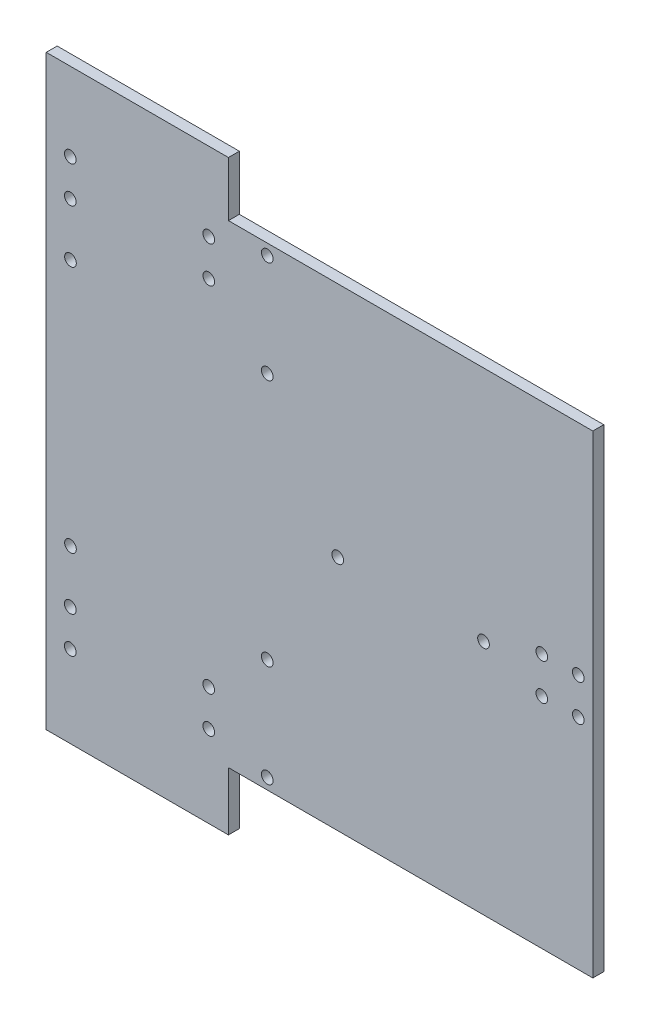
from build123d import *

# Parameters (mm, degrees)
SKETCH1_W           = 150
SKETCH1_H           = 130
BOSS_EXTRUDE1_DEPTH = 3
SKETCH3_W           = 50
SKETCH3_H           = 15
SKETCH3_H_2         = 16
BOSS_EXTRUDE2_DEPTH = 3
SKETCH2_R           = 1.6
CUT_EXTRUDE1_DEPTH  = 10


with BuildPart() as part:
    # Sketch1 → Boss-Extrude1 (new body)
    with BuildSketch(Plane.XY):
        Rectangle(SKETCH1_W, SKETCH1_H)
    extrude(amount=BOSS_EXTRUDE1_DEPTH)

    # Sketch3 → Boss-Extrude2 (add)
    with BuildSketch(Plane(origin=(0, 0, 0), x_dir=(-1, 0, 0), z_dir=(0, 0, -1))):
        with Locations((50, 72.5)):
            Rectangle(SKETCH3_W, SKETCH3_H)
        with Locations((50, -73)):
            Rectangle(SKETCH3_W, SKETCH3_H_2)
    extrude(amount=-BOSS_EXTRUDE2_DEPTH)

    # Sketch2 → Cut-Extrude1 (cut)
    with BuildSketch(Plane.XY.offset(3)):
        with Locations((-30.4, 58.5)):
            Circle(SKETCH2_R)
        with Locations((-68.4, 58.5)):
            Circle(SKETCH2_R)
        with Locations((-68.4, 48.5)):
            Circle(SKETCH2_R)
        with Locations((-30.4, 48.5)):
            Circle(SKETCH2_R)
        with Locations((-68.4, -48.5)):
            Circle(SKETCH2_R)
        with Locations((-68.4, -58.5)):
            Circle(SKETCH2_R)
        with Locations((-30.4, -58.5)):
            Circle(SKETCH2_R)
        with Locations((-30.4, -48.5)):
            Circle(SKETCH2_R)
        with Locations((71, -5)):
            Circle(SKETCH2_R)
        with Locations((71, 5)):
            Circle(SKETCH2_R)
        with Locations((61, -5)):
            Circle(SKETCH2_R)
        with Locations((61, 5)):
            Circle(SKETCH2_R)
        with Locations((-68.35, -34)):
            Circle(SKETCH2_R)
        with Locations((-14.35, -34)):
            Circle(SKETCH2_R)
        with Locations((-14.35, -62)):
            Circle(SKETCH2_R)
        with Locations((-14.35, 62)):
            Circle(SKETCH2_R)
        with Locations((-14.35, 34)):
            Circle(SKETCH2_R)
        with Locations((-68.35, 34)):
            Circle(SKETCH2_R)
        with Locations((45, 0)):
            Circle(SKETCH2_R)
        with Locations((5, 0)):
            Circle(SKETCH2_R)
    extrude(amount=-CUT_EXTRUDE1_DEPTH, mode=Mode.SUBTRACT)


solid = part.part
